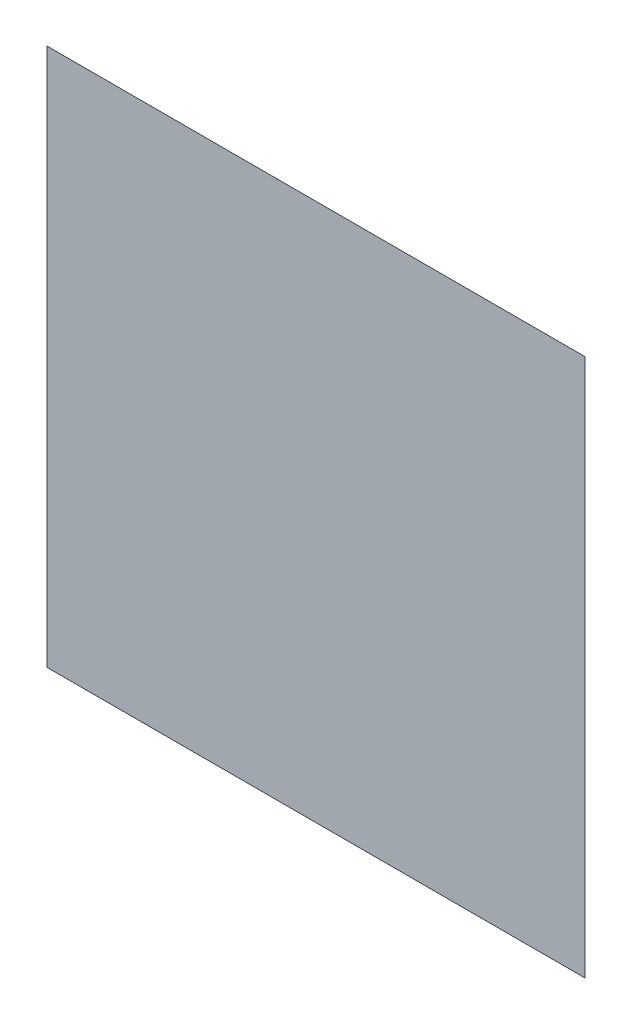
from build123d import *

# Parameters (mm, degrees)
SKETCH1_W           = 1000
SKETCH1_H           = 1000
BOSS_EXTRUDE1_DEPTH = 0.001


with BuildPart() as part:
    # Sketch1 → Boss-Extrude1 (new body)
    with BuildSketch(Plane.XY):
        with Locations((45.454545455, -106.060606061)):
            Rectangle(SKETCH1_W, SKETCH1_H)
    extrude(amount=BOSS_EXTRUDE1_DEPTH)


solid = part.part
